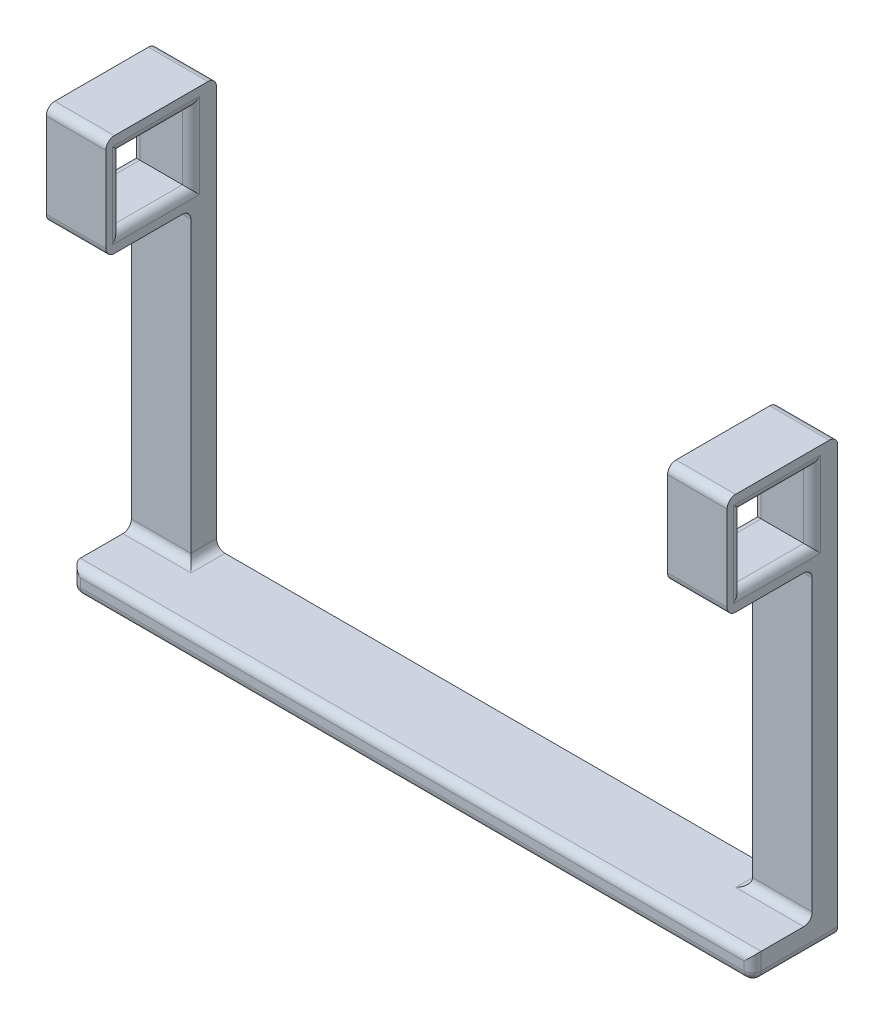
from build123d import *

# Parameters (mm, degrees)
BOSS_EXTRUDE1_DEPTH = 13
SKETCH2_W           = 8.229441325
SKETCH2_H           = 8
CUT_EXTRUDE1_DEPTH  = 100
FILLET1_R           = 1


with BuildPart() as part:
    # Sketch1 → Boss-Extrude1 (new body)
    with BuildSketch(Plane.XY):
        Polygon((0, 0), (40, 0), (40, 51), (33, 51), (33, 3), (0, 3), align=None)
    extrude(amount=BOSS_EXTRUDE1_DEPTH)

    # Sketch2 → Cut-Extrude1 (cut)
    with BuildSketch(Plane(origin=(40, 0, 0), x_dir=(0, 0, -1), z_dir=(1, 0, 0))):
        Polygon((-3, 39), (-13, 39), (-13, 0), (-10, 0), (-10, 3), (-3, 3), align=None)
        with Locations((-7.114720663, 45)):
            Rectangle(SKETCH2_W, SKETCH2_H)
    extrude(amount=-CUT_EXTRUDE1_DEPTH, mode=Mode.SUBTRACT)

    # Mirror2: part across plane


with BuildPart() as part_1:
    add(part.part)
    add(part.part.mirror(Plane(origin=(0, 0, 13), x_dir=(0, 0, 1), z_dir=(1, 0, 0))))

    # Fillet1
    fillet1_edges = [part_1.edges().sort_by_distance(p)[0] for p in [
        (-40, 0, 5),
        (0, 0, 10),
        (40, 0, 5),
        (40, 1.5, 10),
        (40, 41, 7.114720663),
        (40, 45, 11.229441325),
        (40, 49, 7.114720663),
        (40, 45, 3),
        (33, 45, 3),
        (33, 3, 1.5),
        (33, 49, 7.114720663),
        (33, 45, 11.229441325),
        (33, 41, 7.114720663),
        (36.5, 3, 3),
        (0, 3, 10),
        (-36.5, 3, 3),
        (-33, 3, 1.5),
        (-33, 45, 3),
        (-33, 49, 7.114720663),
        (-33, 45, 11.229441325),
        (-33, 41, 7.114720663),
        (-40, 41, 7.114720663),
        (-40, 45, 11.229441325),
        (-40, 49, 7.114720663),
        (-40, 45, 3),
        (-36.5, 51, 0),
        (-36.5, 51, 13),
        (-36.5, 39, 13),
        (-36.5, 39, 3),
        (36.5, 39, 3),
        (36.5, 39, 13),
        (36.5, 51, 13),
        (36.5, 51, 0),
        (-40, 1.5, 10),
    ]]
    fillet(fillet1_edges, radius=FILLET1_R)


solid = part_1.part
